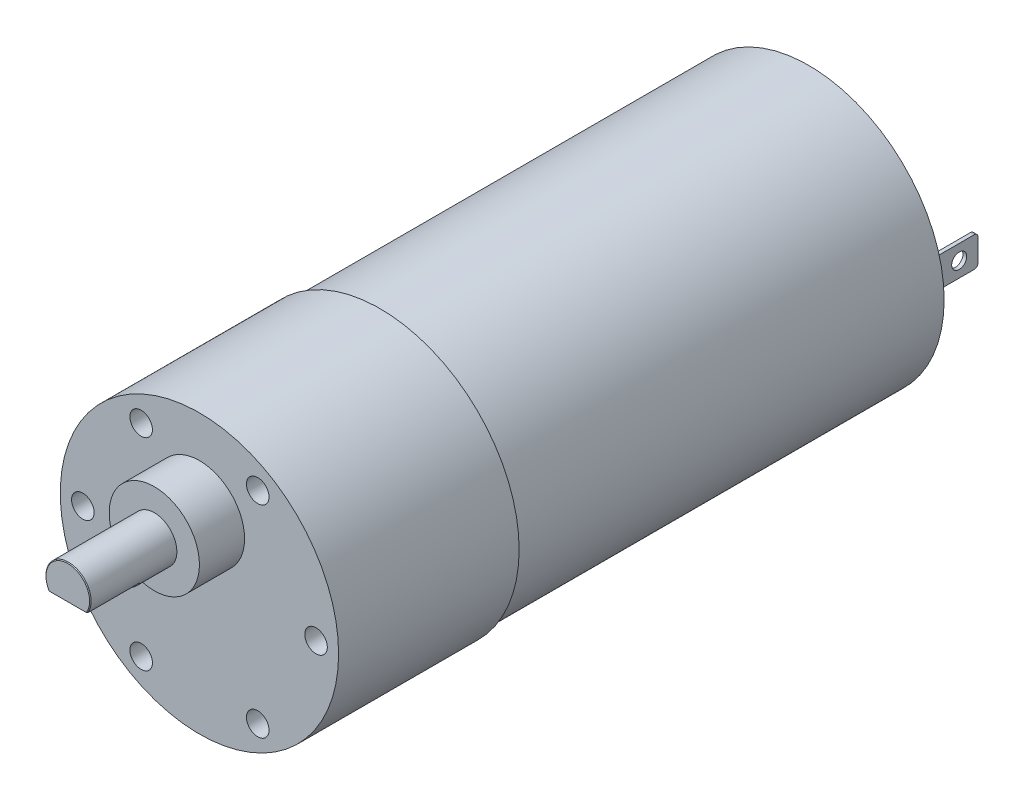
from build123d import *

# Parameters (mm, degrees)
SKETCH_1_R               = 18.5
EXTRUDE_1_DEPTH          = 24
SKETCH_2_R               = 6
EXTRUDE_2_DEPTH          = 6
SKETCH_3_R               = 1.5
CUT_EXTRUDE_1_DEPTH      = 4
SKETCH_4_R               = 3
EXTRUDE_3_DEPTH          = 11.5
CHAMFER_1_SIZE           = 0.1
CUT_EXTRUDE_START        = -7
CUT_EXTRUDE_2_DEPTH      = 7
PATTERN_CIRCULAR_1_COUNT = 6
SKETCH_6_R               = 18
EXTRUDE_4_DEPTH          = 57
SKETCH_7_R               = 6.5
EXTRUDE_5_DEPTH          = 3.5
FILLET_1_R               = 1
SKETCH_8_R               = 1.5
EXTRUDE_6_DEPTH          = 1
SKETCH_9_W               = 0.5
SKETCH_9_H               = 4
EXTRUDE_7_DEPTH          = 8
FILLET_2_R               = 0.5
SKETCH_10_R              = 1
CUT_EXTRUDE_3_DEPTH      = 0.5
CUT_EXTRUDE_START_2      = -0.5
SKETCH_11_R              = 1
CUT_EXTRUDE_4_DEPTH      = 0.5
FILLET_3_R               = 0.8


with BuildPart() as part:
    # 草图1 → 凸台-拉伸1 (new body)
    with BuildSketch(Plane.XY):
        Circle(SKETCH_1_R)
    extrude(amount=EXTRUDE_1_DEPTH)

    # 草图2 → 凸台-拉伸2 (add)
    with BuildSketch(Plane.XY.offset(24)):
        with Locations((0, 7)):
            Circle(SKETCH_2_R)
    extrude(amount=EXTRUDE_2_DEPTH)

    # 草图3 → 切除-拉伸1 (cut)
    with BuildSketch(Plane.XY.offset(24)):
        with Locations((15.5, 0)):
            Circle(SKETCH_3_R)
    cut_extrude_1 = extrude(amount=-CUT_EXTRUDE_1_DEPTH, mode=Mode.SUBTRACT)

    # 草图4 → 凸台-拉伸3 (add)
    with BuildSketch(Plane.XY.offset(30)):
        with Locations((0, 7)):
            Circle(SKETCH_4_R)
    extrude(amount=EXTRUDE_3_DEPTH)

    # 倒角1
    chamfer_1_edges = [part.edges().sort_by_distance(p)[0] for p in [
        (-3, 7, 41.5),
    ]]
    chamfer(chamfer_1_edges, length=CHAMFER_1_SIZE)

    # 草图5 → 切除-拉伸2 (cut)
    with BuildSketch(Plane.XY.offset(41.5).offset(CUT_EXTRUDE_START)):
        with BuildLine():
            Line((-2.589731968, 5.485639298), (2.589731968, 5.485639298))
            ThreePointArc((2.589731968, 5.485639298), (0, 4), (-2.589731968, 5.485639298))
        make_face()
    extrude(amount=CUT_EXTRUDE_2_DEPTH, mode=Mode.SUBTRACT)

    # 阵列(圆周)1: 切除-拉伸1 ×6 about axis
    pattern_circular_1_axis = Axis((0, 0, 47.25), (0, 0, -1))
    for i in range(1, PATTERN_CIRCULAR_1_COUNT):
        add(cut_extrude_1.rotate(pattern_circular_1_axis, i * 360 / PATTERN_CIRCULAR_1_COUNT), mode=Mode.SUBTRACT)

    # 草图6 → 凸台-拉伸4 (add)
    with BuildSketch(Plane(origin=(0, 0, 0), x_dir=(-1, 0, 0), z_dir=(0, 0, -1))):
        Circle(SKETCH_6_R)
    extrude(amount=EXTRUDE_4_DEPTH)

    # 草图7 → 凸台-拉伸5 (add)
    with BuildSketch(Plane(origin=(0, 0, -57), x_dir=(-1, 0, 0), z_dir=(0, 0, -1))):
        Circle(SKETCH_7_R)
    extrude(amount=EXTRUDE_5_DEPTH)

    # 圆角1
    fillet_1_edges = [part.edges().sort_by_distance(p)[0] for p in [
        (6.5, 0, -60.5),
    ]]
    fillet(fillet_1_edges, radius=FILLET_1_R)

    # 草图8 → 凸台-拉伸6 (add)
    with BuildSketch(Plane(origin=(0, 0, -60.5), x_dir=(-1, 0, 0), z_dir=(0, 0, -1))):
        Circle(SKETCH_8_R)
    extrude(amount=EXTRUDE_6_DEPTH)

    # 草图9 → 凸台-拉伸7 (add)
    with BuildSketch(Plane(origin=(0, 0, -57), x_dir=(-1, 0, 0), z_dir=(0, 0, -1))):
        with Locations((14.25, 0)):
            Rectangle(SKETCH_9_W, SKETCH_9_H)
        with Locations((-14.25, 0)):
            Rectangle(SKETCH_9_W, SKETCH_9_H)
    extrude(amount=EXTRUDE_7_DEPTH)

    # 圆角2
    fillet_2_edges = [part.edges().sort_by_distance(p)[0] for p in [
        (14.25, 2, -65),
        (14.25, -2, -65),
        (-14.25, -2, -65),
        (-14.25, 2, -65),
    ]]
    fillet(fillet_2_edges, radius=FILLET_2_R)

    # 草图10 → 切除-拉伸3 (cut)
    with BuildSketch(Plane.ZY.offset(14.5)):
        with Locations((-62.5, 0)):
            Circle(SKETCH_10_R)
    extrude(amount=-CUT_EXTRUDE_3_DEPTH, mode=Mode.SUBTRACT)

    # 草图11 → 切除-拉伸4 (cut)
    with BuildSketch(Plane(origin=(14.5, 0, 0), x_dir=(0, 0, -1), z_dir=(1, 0, 0)).offset(CUT_EXTRUDE_START_2)):
        with Locations((62.5, 0)):
            Circle(SKETCH_11_R)
    extrude(amount=CUT_EXTRUDE_4_DEPTH, mode=Mode.SUBTRACT)

    # 圆角3
    fillet_3_edges = [part.edges().sort_by_distance(p)[0] for p in [
        (1.5, 0, -61.5),
    ]]
    fillet(fillet_3_edges, radius=FILLET_3_R)


solid = part.part
